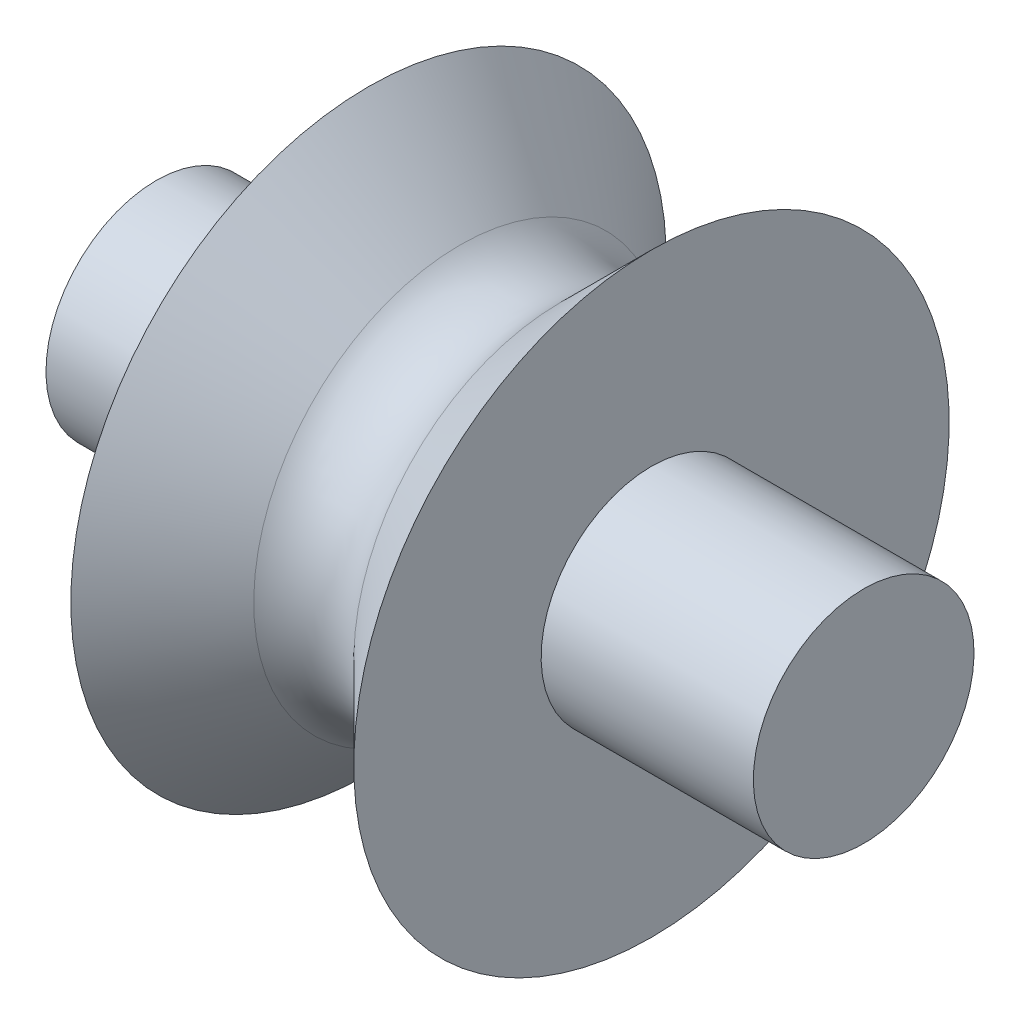
from build123d import *


with BuildPart() as part:
    # Sketch1 → Revolve1 (revolve)
    with BuildSketch(Plane.XY):
        with BuildLine():
            Line((0, 0), (7.62, 0))
            Line((7.62, 0), (7.62, 6.726876964))
            Line((7.62, 6.726876964), (10.903948776, 3.442928188))
            ThreePointArc((10.903948776, 3.442928188), (12.7, 2.698979412), (14.496051224, 3.442928188))
            Line((14.496051224, 3.442928188), (17.78, 6.726876964))
            Line((17.78, 6.726876964), (17.78, 0))
            Line((17.78, 0), (25.4, 0))
            Line((25.4, 0), (25.4, -3.9624))
            Line((25.4, -3.9624), (0, -3.9624))
            Line((0, -3.9624), (0, 0))
        make_face()
    revolve(axis=Axis((25.4, -3.9624, 0), (-1, 0, 0)))


solid = part.part
